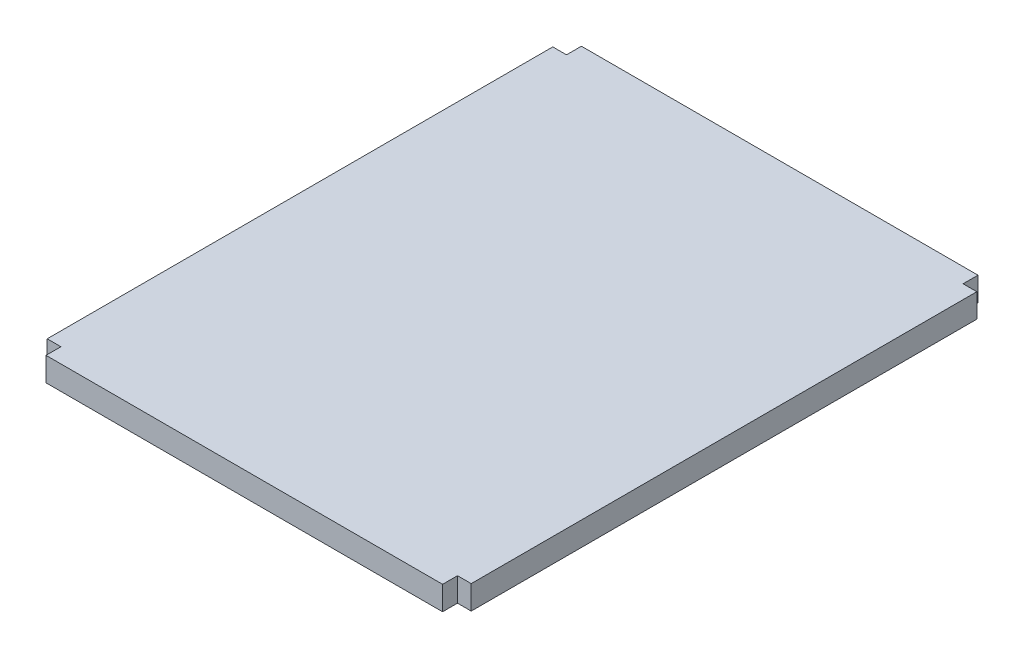
from build123d import *

# Parameters (mm, degrees)
BOSS_EXTRUDE1_DEPTH = 127


with BuildPart() as part:
    # Sketch1 → Boss-Extrude1 (new body)
    with BuildSketch(Plane(origin=(0, 0, 0), x_dir=(1, 0, 0), z_dir=(0, 1, 0))):
        Polygon((-1057.148, -1427.226), (1057.148, -1427.226), (1057.148, -1347.724), (1130.3, -1347.724), (1130.3, 1347.724), (1057.148, 1347.724), (1057.148, 1427.226), (-1057.148, 1427.226), (-1057.148, 1347.724), (-1130.3, 1347.724), (-1130.3, -1347.724), (-1057.148, -1347.724), align=None)
    extrude(amount=BOSS_EXTRUDE1_DEPTH)


solid = part.part
